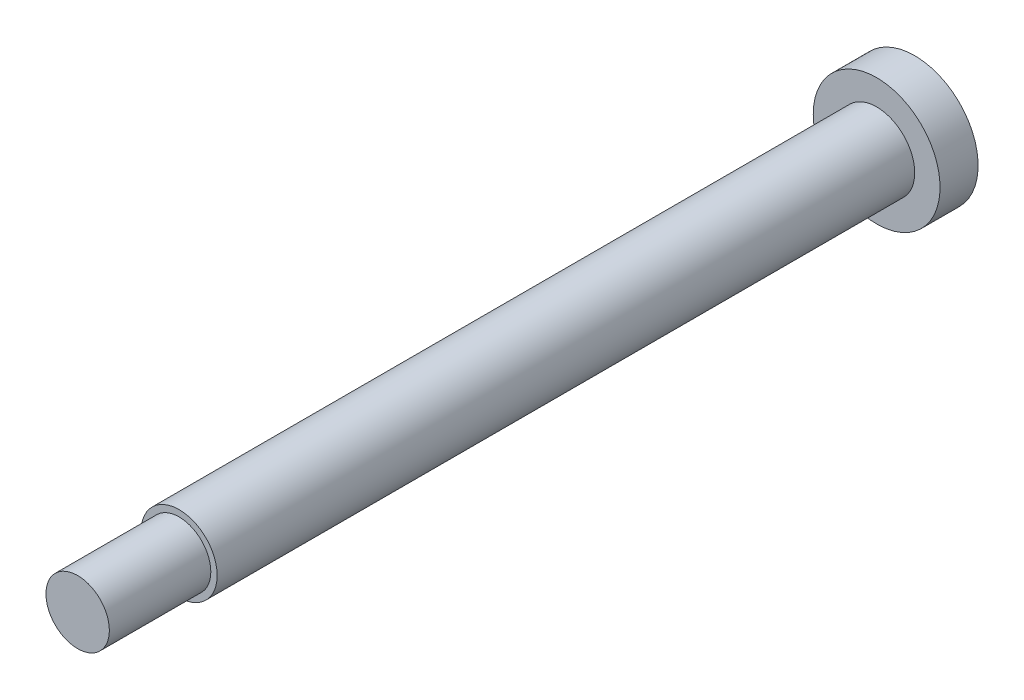
from build123d import *

# Parameters (mm, degrees)
SKETCH_1_R      = 3
EXTRUDE_1_DEPTH = 55
SKETCH_2_R      = 2.5
EXTRUDE_2_DEPTH = 8
SKETCH_3_R      = 5
EXTRUDE_3_DEPTH = 3


with BuildPart() as part:
    # 草图1 → 凸台-拉伸1 (new body)
    with BuildSketch(Plane.XY):
        Circle(SKETCH_1_R)
    extrude(amount=EXTRUDE_1_DEPTH)

    # 草图2 → 凸台-拉伸2 (add)
    with BuildSketch(Plane.XY.offset(55)):
        Circle(SKETCH_2_R)
    extrude(amount=EXTRUDE_2_DEPTH)

    # 草图3 → 凸台-拉伸3 (add)
    with BuildSketch(Plane(origin=(0, 0, 0), x_dir=(-1, 0, 0), z_dir=(0, 0, -1))):
        Circle(SKETCH_3_R)
    extrude(amount=EXTRUDE_3_DEPTH)


solid = part.part
